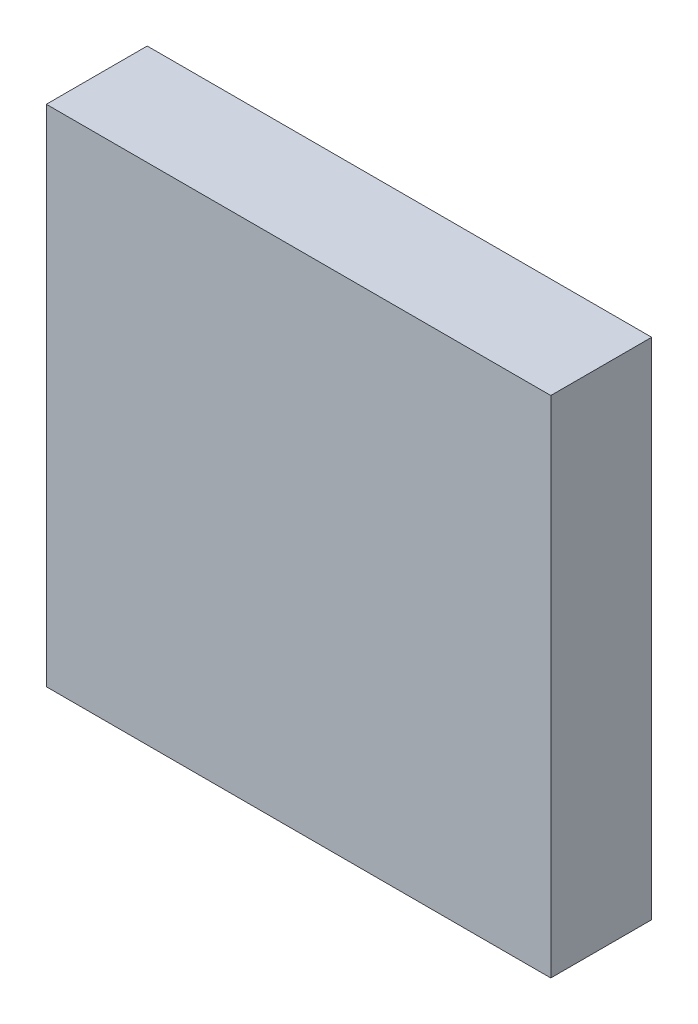
from build123d import *

# Parameters (mm, degrees)
SKETCH1_W           = 25
SKETCH1_H           = 25
BOSS_EXTRUDE1_DEPTH = 5


with BuildPart() as part:
    # Sketch1 → Boss-Extrude1 (new body)
    with BuildSketch(Plane(origin=(0, 0, 0), x_dir=(0, 1, 0), z_dir=(0, 0, 1))):
        Rectangle(SKETCH1_W, SKETCH1_H)
    extrude(amount=BOSS_EXTRUDE1_DEPTH)


solid = part.part
